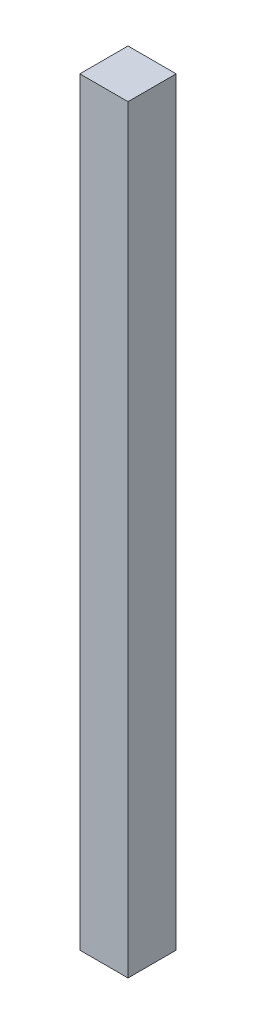
from build123d import *

# Parameters (mm, degrees)
SKETCH1_W           = 25.4
SKETCH1_H           = 25.4
BOSS_EXTRUDE1_DEPTH = 400


with BuildPart() as part:
    # Sketch1 → Boss-Extrude1 (new body)
    with BuildSketch(Plane(origin=(0, 0, 0), x_dir=(1, 0, 0), z_dir=(0, 1, 0))):
        with Locations((-27.135508984, 5.913615805)):
            Rectangle(SKETCH1_W, SKETCH1_H)
    extrude(amount=BOSS_EXTRUDE1_DEPTH)


solid = part.part
